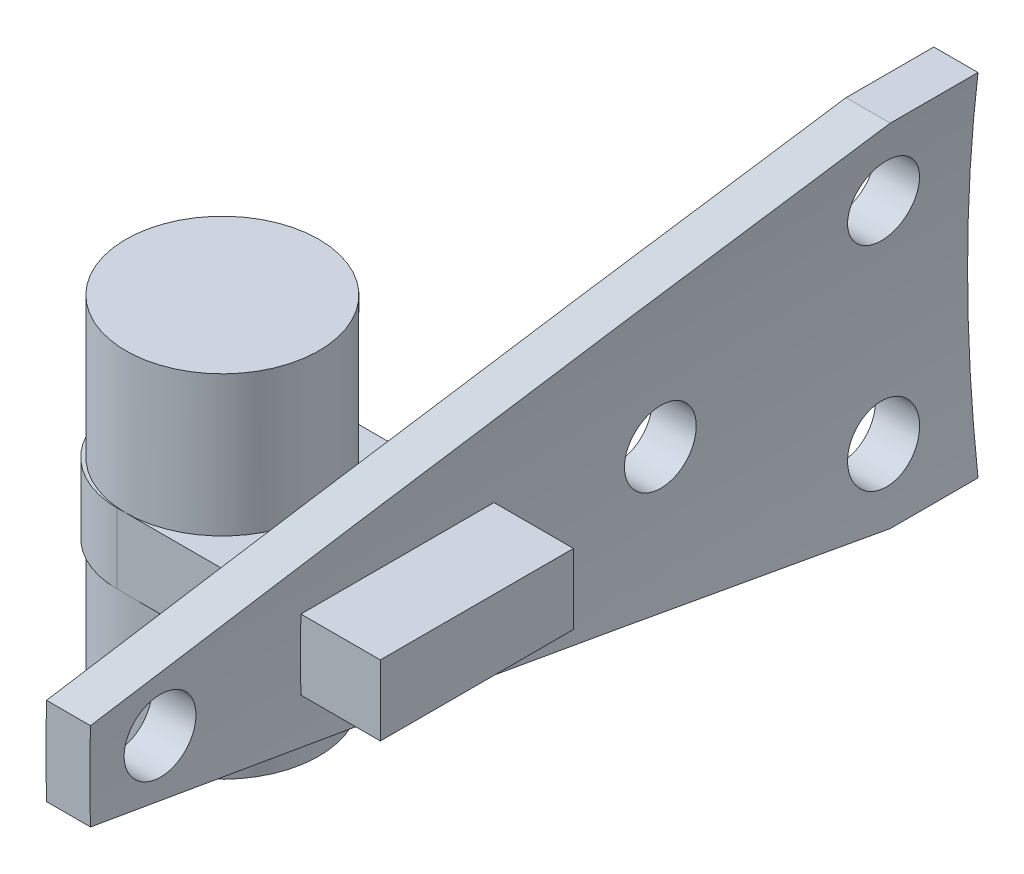
from build123d import *

# Parameters (mm, degrees)
BOSS_EXTRUDE1_DEPTH             = 50
SKETCH2_W                       = 109.146932236
SKETCH2_H                       = 60.735636093
CUT_EXTRUDE1_DEPTH              = 88.05
F_20_0_161_DIAMETER_HOLE1_D     = 4.0894
F_20_0_161_DIAMETER_HOLE1_DEPTH = 87.05
SKETCH7_W                       = 11
SKETCH7_H                       = 4
BOSS_EXTRUDE2_DEPTH             = 20
FILLET1_R                       = 2
SKETCH8_R                       = 5.5
BOSS_EXTRUDE3_DEPTH             = 8
BOSS_EXTRUDE3_DEPTH_BACK        = 12
FILLET2_R                       = 5


with BuildPart() as part:
    # Sketch1 → Boss-Extrude1 (new body)
    with BuildSketch(Plane.XY):
        with BuildLine():
            Line((-86.473709878, 10), (-83.956551263, 10))
            ThreePointArc((-83.956551263, 10), (-84.55, 0), (-83.956551263, -10))
            Line((-83.956551263, -10), (-86.473709878, -10))
            ThreePointArc((-86.473709878, -10), (-87.05, 0), (-86.473709878, 10))
        make_face()
    extrude(amount=BOSS_EXTRUDE1_DEPTH)

    # Sketch2 → Cut-Extrude1 (cut, through all)
    with BuildSketch(Plane(origin=(0, 0, 0), x_dir=(0, 0, -1), z_dir=(1, 0, 0))):
        with Locations((-34.220207601, -2.682367057)):
            Rectangle(SKETCH2_W, SKETCH2_H)
        Polygon((0, 10), (0, -10), (-5, -10), (-50, -2.5), (-50, 2.5), (-5, 10), align=None, mode=Mode.SUBTRACT)
    extrude(amount=-CUT_EXTRUDE1_DEPTH, mode=Mode.SUBTRACT)

    # #20 (0.161) Diameter Hole1
    with Locations(Plane(origin=(0, 0, 0), x_dir=(0, 0, -1), z_dir=(1, 0, 0))):
        with Locations((-46, 0), (-5, 6), (-5, -6), (-17.5, 0)):
            Hole(F_20_0_161_DIAMETER_HOLE1_D / 2, depth=F_20_0_161_DIAMETER_HOLE1_DEPTH)

    # Sketch7 → Boss-Extrude2 (add)
    with BuildSketch(Plane(origin=(-80, 0, -87.99983), x_dir=(0, 0, -1), z_dir=(1, 0, 0))):
        with Locations((-120.49983, 0)):
            Rectangle(SKETCH7_W, SKETCH7_H)
    extrude(amount=-BOSS_EXTRUDE2_DEPTH)

    # Fillet1
    fillet1_edges = [part.edges().sort_by_distance(p)[0] for p in [
        (-87.027021666, -2, 32.5),
        (-87.05, 0, 27),
        (-87.027021666, 2, 32.5),
        (-87.05, 0, 38),
    ]]
    fillet(fillet1_edges, radius=FILLET1_R)

    # Sketch8 → Boss-Extrude3 (add, two sides)
    with BuildSketch(Plane.XZ.offset(2)) as boss_extrude3_sk:
        with Locations((-94.5, 32.5)):
            Circle(SKETCH8_R)
    extrude(amount=BOSS_EXTRUDE3_DEPTH)
    extrude(boss_extrude3_sk.sketch, amount=-BOSS_EXTRUDE3_DEPTH_BACK)

    # Fillet2
    fillet2_edges = [part.edges().sort_by_distance(p)[0] for p in [
        (-100, 0, 38),
        (-100, 0, 27),
    ]]
    fillet(fillet2_edges, radius=FILLET2_R)


solid = part.part
